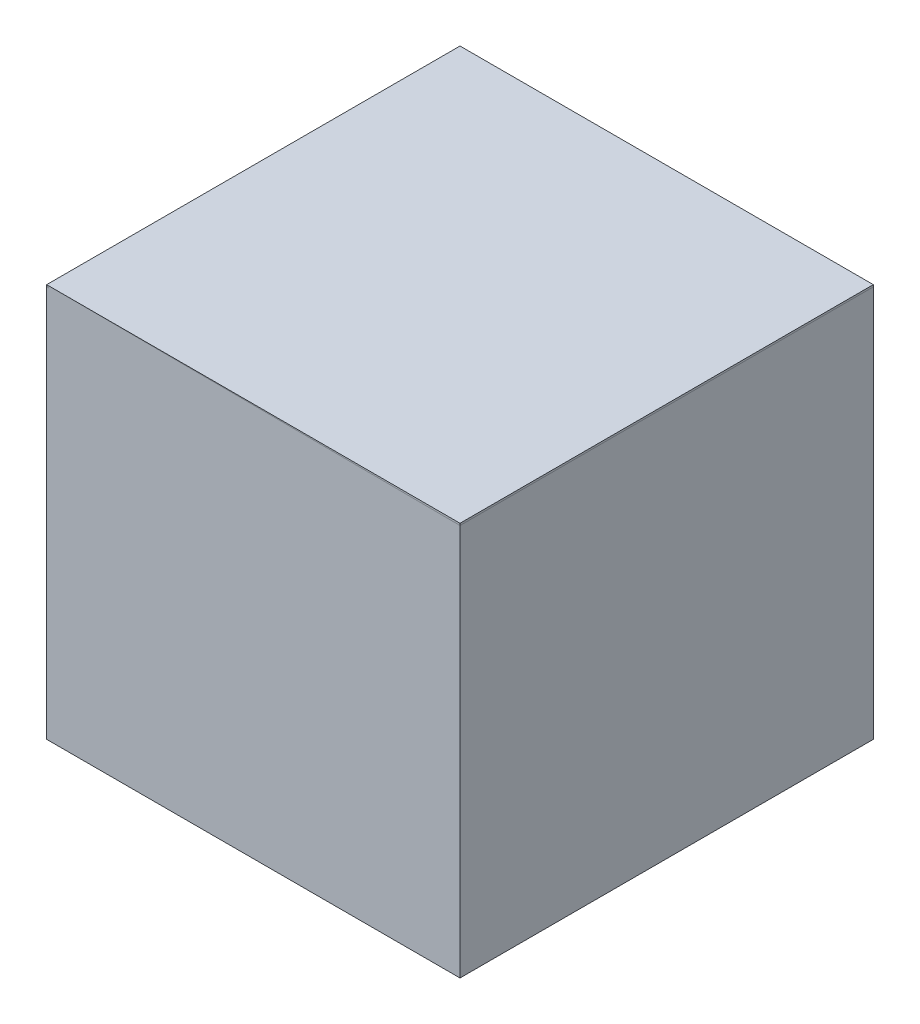
from build123d import *

# Parameters (mm, degrees)
SKETCH2_W           = 1060.036
SKETCH2_H           = 1060.036
SKETCH2_W_2         = 1050.036
SKETCH2_H_2         = 1050.036
EXTRUDE_THIN1_DEPTH = 1010
SKETCH4_W           = 1060.036
SKETCH4_H           = 1060.036
BOSS_EXTRUDE1_DEPTH = 5


with BuildPart() as part:
    # Sketch2 → Extrude-Thin1 (new body)
    with BuildSketch(Plane(origin=(0, 1030, 0), x_dir=(1, 0, 0), z_dir=(0, 1, 0))):
        with Locations((599.511716421, 0.434855008)):
            Rectangle(SKETCH2_W, SKETCH2_H)
        with Locations((599.511716421, 0.434855008)):
            Rectangle(SKETCH2_W_2, SKETCH2_H_2, mode=Mode.SUBTRACT)
    extrude(amount=-EXTRUDE_THIN1_DEPTH)


with BuildPart() as body_2:
    # Sketch4 → Boss-Extrude1 (new body)
    with BuildSketch(Plane(origin=(0, 1025, 0), x_dir=(1, 0, 0), z_dir=(0, 1, 0))):
        with Locations((599.511716421, 0.434855008)):
            Rectangle(SKETCH4_W, SKETCH4_H)
    extrude(amount=BOSS_EXTRUDE1_DEPTH)


solid = Compound([part.part, body_2.part])
